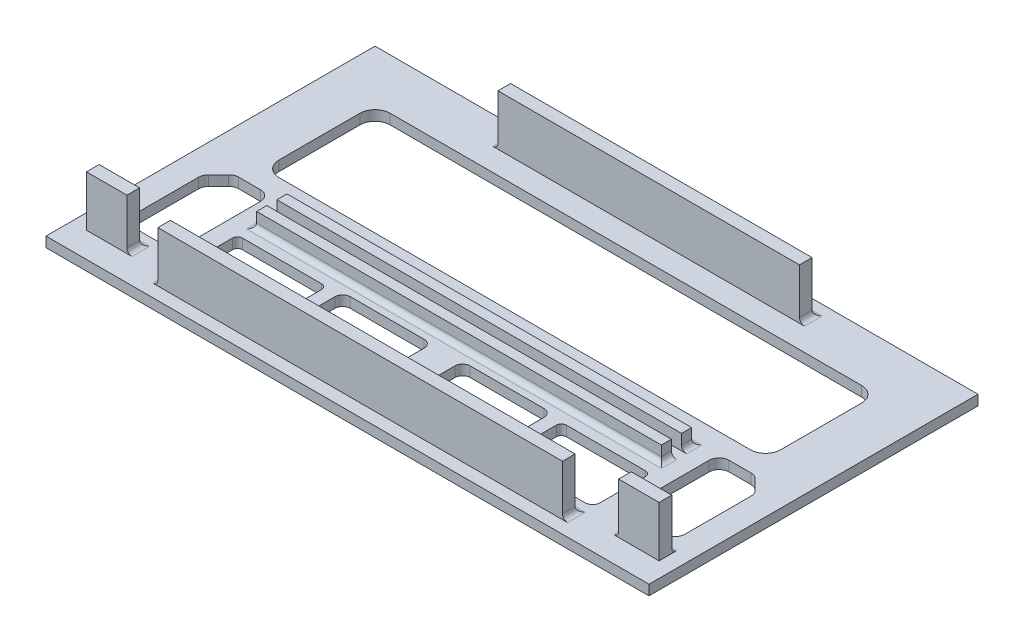
from build123d import *

# Parameters (mm, degrees)
SKETCH1_W           = 119.2
SKETCH1_H           = 65.04
BOSS_EXTRUDE1_DEPTH = 2
SKETCH2_W           = 80
SKETCH2_H           = 2
SKETCH2_W_2         = 59.6
SKETCH2_H_2         = 2.5
BOSS_EXTRUDE2_DEPTH = 10
FILLET1_R           = 1
SKETCH3_W           = 80
SKETCH3_H           = 2
CUT_EXTRUDE1_DEPTH  = 7
SKETCH4_W           = 80
SKETCH4_H           = 2.5
SKETCH4_W_2         = 8
BOSS_EXTRUDE3_DEPTH = 10
FILLET2_R           = 1
FILLET3_R           = 1
CUT_EXTRUDE2_DEPTH  = 10
CUT_EXTRUDE3_DEPTH  = 10


with BuildPart() as part:
    # Sketch1 → Boss-Extrude1 (new body)
    with BuildSketch(Plane(origin=(0, 0, 0), x_dir=(1, 0, 0), z_dir=(0, 1, 0))):
        Rectangle(SKETCH1_W, SKETCH1_H)
    extrude(amount=BOSS_EXTRUDE1_DEPTH)

    # Sketch2 → Boss-Extrude2 (add)
    with BuildSketch(Plane(origin=(0, 2, 0), x_dir=(1, 0, 0), z_dir=(0, 1, 0))):
        with Locations((0, -9.48)):
            Rectangle(SKETCH2_W, SKETCH2_H)
        with Locations((0, -5.48)):
            Rectangle(SKETCH2_W, SKETCH2_H)
        with Locations((0, 28.27)):
            Rectangle(SKETCH2_W_2, SKETCH2_H_2)
    extrude(amount=BOSS_EXTRUDE2_DEPTH)

    # Fillet1
    fillet1_edges = [part.edges().sort_by_distance(p)[0] for p in [
        (40, 2, 9.48),
        (0, 2, 10.48),
        (-40, 2, 9.48),
        (40, 2, 5.48),
        (0, 2, 4.48),
        (-40, 2, 5.48),
        (-29.8, 2, -28.27),
        (29.8, 2, -28.27),
        (0, 2, -29.52),
    ]]
    fillet(fillet1_edges, radius=FILLET1_R)

    # Sketch3 → Cut-Extrude1 (cut)
    with BuildSketch(Plane(origin=(0, 12, 0), x_dir=(1, 0, 0), z_dir=(0, 1, 0))):
        with Locations((0, -5.48)):
            Rectangle(SKETCH3_W, SKETCH3_H)
        with Locations((0, -9.48)):
            Rectangle(SKETCH3_W, SKETCH3_H)
    extrude(amount=-CUT_EXTRUDE1_DEPTH, mode=Mode.SUBTRACT)

    # Sketch4 → Boss-Extrude3 (add)
    with BuildSketch(Plane(origin=(0, 2, 0), x_dir=(1, 0, 0), z_dir=(0, 1, 0))):
        with Locations((0, -28.77)):
            Rectangle(SKETCH4_W, SKETCH4_H)
        with Locations((52.6, -26.27)):
            Rectangle(SKETCH4_W_2, SKETCH4_H)
    boss_extrude3 = extrude(amount=BOSS_EXTRUDE3_DEPTH)

    # Fillet2
    fillet2_edges = [part.edges().sort_by_distance(p)[0] for p in [
        (-40, 2, 28.77),
        (48.6, 2, 26.27),
        (52.6, 2, 25.02),
        (40, 2, 28.77),
        (0, 2, 27.52),
    ]]
    fillet(fillet2_edges, radius=FILLET2_R)

    # Mirror1: Boss-Extrude3 across plane
    add(boss_extrude3.mirror(Plane.ZY))

    # Fillet3
    fillet3_edges = [part.edges().sort_by_distance(p)[0] for p in [
        (-48.6, 2, 26.27),
        (-52.6, 2, 25.02),
    ]]
    fillet(fillet3_edges, radius=FILLET3_R)

    # Sketch5 → Cut-Extrude2 (cut)
    with BuildSketch(Plane(origin=(0, 2, 0), x_dir=(1, 0, 0), z_dir=(0, 1, 0))):
        with BuildLine():
            Line((46.6, 22.52), (6.311514948, 22.52))
            Line((6.311514948, 22.52), (-46.6, 22.52))
            ThreePointArc((-46.6, 22.52), (-48.721320344, 21.641320344), (-49.6, 19.52))
            Line((-49.6, 19.52), (-49.6, 3.52))
            ThreePointArc((-49.6, 3.52), (-48.721320344, 1.398679656), (-46.6, 0.52))
            Line((-46.6, 0.52), (46.6, 0.52))
            ThreePointArc((46.6, 0.52), (48.721320344, 1.398679656), (49.6, 3.52))
            Line((49.6, 3.52), (49.6, 19.52))
            ThreePointArc((49.6, 19.52), (48.721320344, 21.641320344), (46.6, 22.52))
        make_face()
    extrude(amount=-CUT_EXTRUDE2_DEPTH, mode=Mode.SUBTRACT)

    # Sketch6 → Cut-Extrude3 (cut)
    with BuildSketch(Plane(origin=(0, 2, 0), x_dir=(1, 0, 0), z_dir=(0, 1, 0))):
        with BuildLine():
            Line((54.014213562, -5.94084617), (52.045315698, -3.971948306))
            ThreePointArc((52.045315698, -3.971948306), (51.396469, -3.538402803), (50.631102135, -3.386161868))
            Line((50.631102135, -3.386161868), (46.32782558, -3.386161868))
            ThreePointArc((46.32782558, -3.386161868), (44.913612017, -3.971948306), (44.32782558, -5.386161868))
            Line((44.32782558, -5.386161868), (44.32782558, -20.397912268))
            ThreePointArc((44.32782558, -20.397912268), (44.913612017, -21.812125831), (46.32782558, -22.397912268))
            Line((46.32782558, -22.397912268), (52.6, -22.397912268))
            ThreePointArc((52.6, -22.397912268), (54.014213562, -21.812125831), (54.6, -20.397912268))
            Line((54.6, -20.397912268), (54.6, -7.355059733))
            ThreePointArc((54.6, -7.355059733), (54.447759065, -6.589692868), (54.014213562, -5.94084617))
        make_face()
        with BuildLine():
            Line((39.82782558, -13.44932419), (24.210760832, -13.44932419))
            ThreePointArc((24.210760832, -13.44932419), (23.503654051, -13.742217409), (23.210760832, -14.44932419))
            Line((23.210760832, -14.44932419), (23.210760832, -23.393622011))
            ThreePointArc((23.210760832, -23.393622011), (23.650100661, -24.454282183), (24.710760832, -24.893622011))
            Line((24.710760832, -24.893622011), (39.32782558, -24.893622011))
            ThreePointArc((39.32782558, -24.893622011), (40.388485752, -24.454282183), (40.82782558, -23.393622011))
            Line((40.82782558, -23.393622011), (40.82782558, -14.44932419))
            ThreePointArc((40.82782558, -14.44932419), (40.534932361, -13.742217409), (39.82782558, -13.44932419))
        make_face()
        with BuildLine():
            Line((4.043952302, -24.893622011), (19.660852384, -24.893622011))
            ThreePointArc((19.660852384, -24.893622011), (20.367959165, -24.600728792), (20.660852384, -23.893622011))
            Line((20.660852384, -23.893622011), (20.660852384, -14.321364431))
            ThreePointArc((20.660852384, -14.321364431), (20.221512556, -13.260704259), (19.160852384, -12.821364431))
            Line((19.160852384, -12.821364431), (4.543952302, -12.821364431))
            ThreePointArc((4.543952302, -12.821364431), (3.48329213, -13.260704259), (3.043952302, -14.321364431))
            Line((3.043952302, -14.321364431), (3.043952302, -23.893622011))
            ThreePointArc((3.043952302, -23.893622011), (3.336845521, -24.600728792), (4.043952302, -24.893622011))
        make_face()
        with BuildLine():
            Line((-4.043952302, -24.893622011), (-19.660852384, -24.893622011))
            ThreePointArc((-19.660852384, -24.893622011), (-20.367959165, -24.600728792), (-20.660852384, -23.893622011))
            Line((-20.660852384, -23.893622011), (-20.660852384, -14.321364431))
            ThreePointArc((-20.660852384, -14.321364431), (-20.221512556, -13.260704259), (-19.160852384, -12.821364431))
            Line((-19.160852384, -12.821364431), (-4.543952302, -12.821364431))
            ThreePointArc((-4.543952302, -12.821364431), (-3.48329213, -13.260704259), (-3.043952302, -14.321364431))
            Line((-3.043952302, -14.321364431), (-3.043952302, -23.893622011))
            ThreePointArc((-3.043952302, -23.893622011), (-3.336845521, -24.600728792), (-4.043952302, -24.893622011))
        make_face()
        with BuildLine():
            Line((-39.32782558, -24.893622011), (-24.710760832, -24.893622011))
            ThreePointArc((-24.710760832, -24.893622011), (-23.650100661, -24.454282183), (-23.210760832, -23.393622011))
            Line((-23.210760832, -23.393622011), (-23.210760832, -14.44932419))
            ThreePointArc((-23.210760832, -14.44932419), (-23.503654051, -13.742217409), (-24.210760832, -13.44932419))
            Line((-24.210760832, -13.44932419), (-39.82782558, -13.44932419))
            ThreePointArc((-39.82782558, -13.44932419), (-40.534932361, -13.742217409), (-40.82782558, -14.44932419))
            Line((-40.82782558, -14.44932419), (-40.82782558, -23.393622011))
            ThreePointArc((-40.82782558, -23.393622011), (-40.388485752, -24.454282183), (-39.32782558, -24.893622011))
        make_face()
        with BuildLine():
            Line((-44.32782558, -5.386161868), (-44.32782558, -20.397912268))
            ThreePointArc((-44.32782558, -20.397912268), (-44.913612017, -21.812125831), (-46.32782558, -22.397912268))
            Line((-46.32782558, -22.397912268), (-52.6, -22.397912268))
            ThreePointArc((-52.6, -22.397912268), (-54.014213562, -21.812125831), (-54.6, -20.397912268))
            Line((-54.6, -20.397912268), (-54.6, -7.355059733))
            ThreePointArc((-54.6, -7.355059733), (-54.447759065, -6.589692868), (-54.014213562, -5.94084617))
            Line((-54.014213562, -5.94084617), (-52.045315698, -3.971948306))
            ThreePointArc((-52.045315698, -3.971948306), (-51.396469, -3.538402803), (-50.631102135, -3.386161868))
            Line((-50.631102135, -3.386161868), (-46.32782558, -3.386161868))
            ThreePointArc((-46.32782558, -3.386161868), (-44.913612017, -3.971948306), (-44.32782558, -5.386161868))
        make_face()
    extrude(amount=-CUT_EXTRUDE3_DEPTH, mode=Mode.SUBTRACT)


solid = part.part
